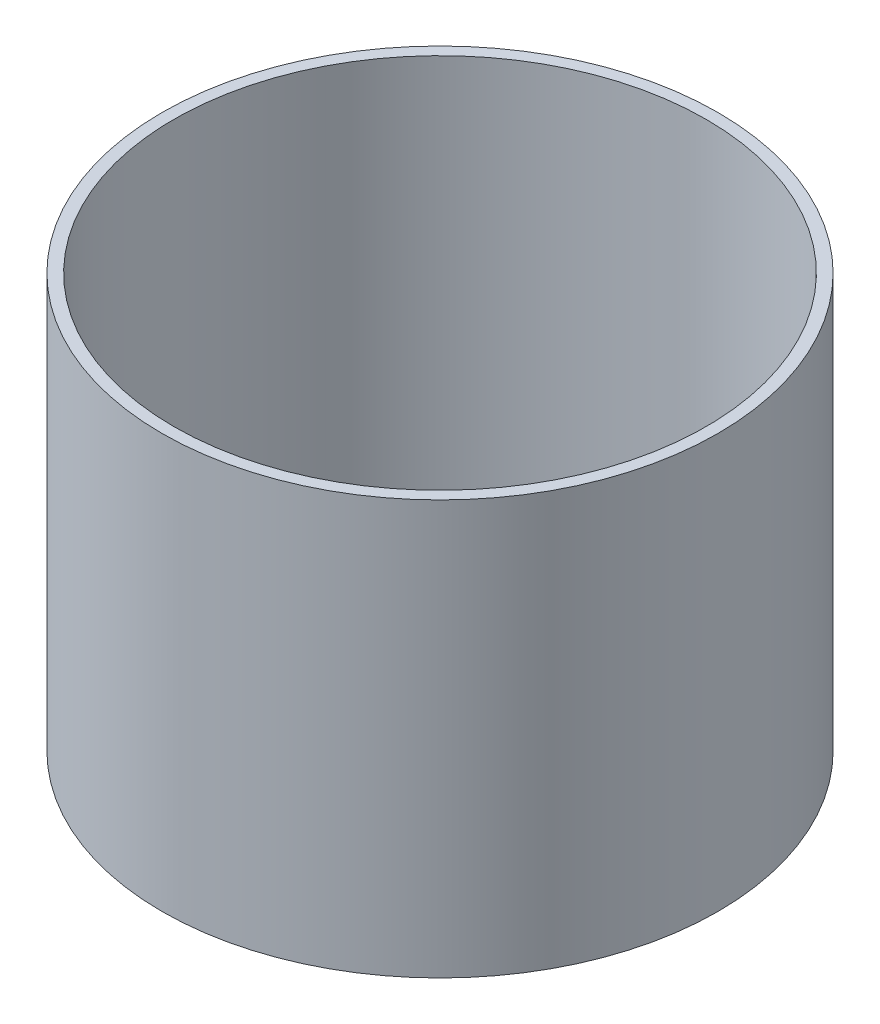
from build123d import *

# Parameters (mm, degrees)
SKETCH3_R           = 119.38
SKETCH3_R_2         = 114.3
BOSS_EXTRUDE1_DEPTH = 177.8


with BuildPart() as part:
    # Sketch3 → Boss-Extrude1 (new body)
    with BuildSketch(Plane(origin=(0, 0, 0), x_dir=(1, 0, 0), z_dir=(0, 1, 0))):
        Circle(SKETCH3_R)
        Circle(SKETCH3_R_2, mode=Mode.SUBTRACT)
    extrude(amount=BOSS_EXTRUDE1_DEPTH)


solid = part.part
